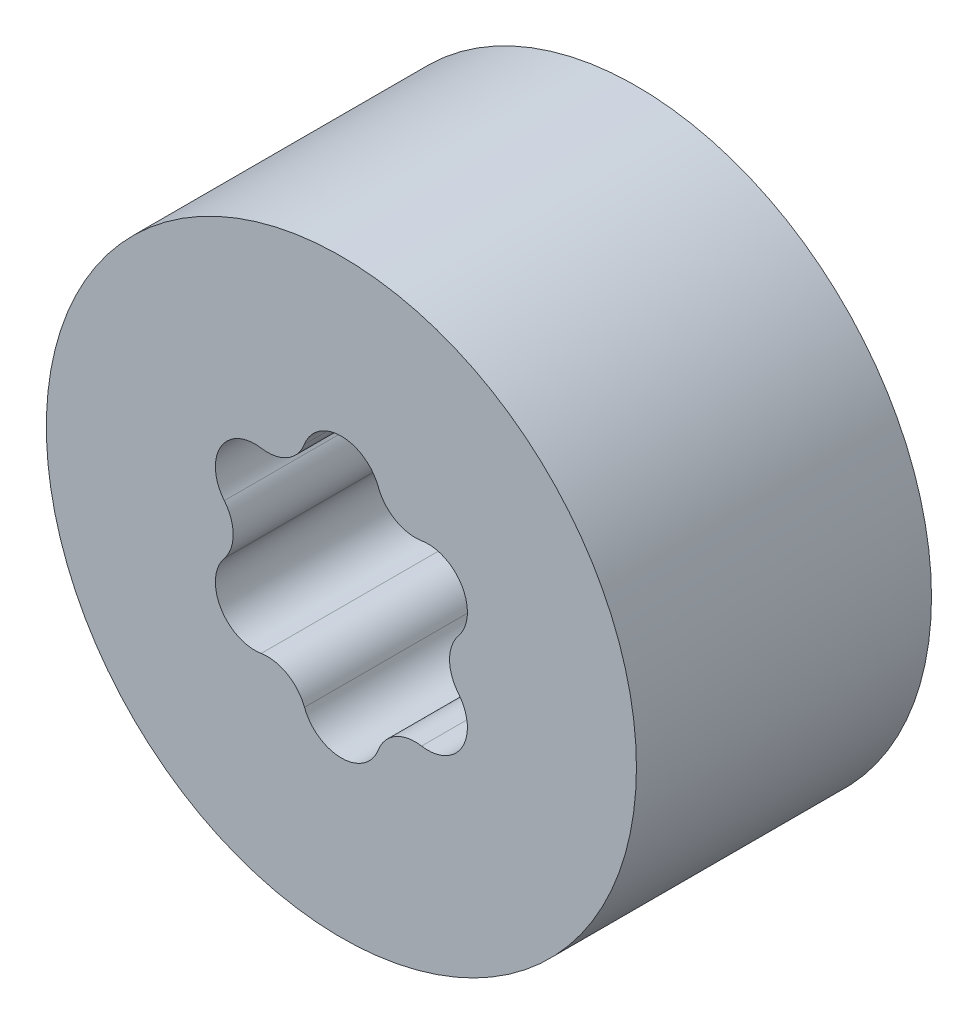
from build123d import *

# Parameters (mm, degrees)
SKETCH1_R           = 19.05
SKETCH1_R_2         = 5
BOSS_EXTRUDE1_DEPTH = 9.525
CUT_EXTRUDE1_DEPTH  = 20.05


with BuildPart() as part:
    # Sketch1 → Boss-Extrude1 (new body, symmetric)
    with BuildSketch(Plane.XY):
        Circle(SKETCH1_R)
        Circle(SKETCH1_R_2, mode=Mode.SUBTRACT)
    extrude(amount=BOSS_EXTRUDE1_DEPTH, both=True)

    # Sketch2 → Cut-Extrude1 (cut, through all)
    with BuildSketch(Plane(origin=(0, 0, -9.525), x_dir=(-1, 0, 0), z_dir=(0, 0, -1))):
        with BuildLine():
            ThreePointArc((-2.382933771, -7.353538376), (-3.492043555, -6.04839686), (-5.176884156, -5.740450369))
            ThreePointArc((-5.176884156, -5.740450369), (-7.794228634, -4.5), (-7.559817926, -1.613088007))
            ThreePointArc((-7.559817926, -1.613088007), (-6.984087111, 0), (-7.559817926, 1.613088007))
            ThreePointArc((-7.559817926, 1.613088007), (-7.794228634, 4.5), (-5.176884156, 5.740450369))
            ThreePointArc((-5.176884156, 5.740450369), (-3.492043555, 6.04839686), (-2.382933771, 7.353538376))
            ThreePointArc((-2.382933771, 7.353538376), (0, 9), (2.382933771, 7.353538376))
            ThreePointArc((2.382933771, 7.353538376), (3.492043555, 6.04839686), (5.176884156, 5.740450369))
            ThreePointArc((5.176884156, 5.740450369), (7.794228634, 4.5), (7.559817926, 1.613088007))
            ThreePointArc((7.559817926, 1.613088007), (6.984087111, 0), (7.559817926, -1.613088007))
            ThreePointArc((7.559817926, -1.613088007), (7.794228634, -4.5), (5.176884156, -5.740450369))
            ThreePointArc((5.176884156, -5.740450369), (3.492043555, -6.04839686), (2.382933771, -7.353538376))
            ThreePointArc((2.382933771, -7.353538376), (0, -9), (-2.382933771, -7.353538376))
        make_face()
    extrude(amount=-CUT_EXTRUDE1_DEPTH, mode=Mode.SUBTRACT)


solid = part.part
